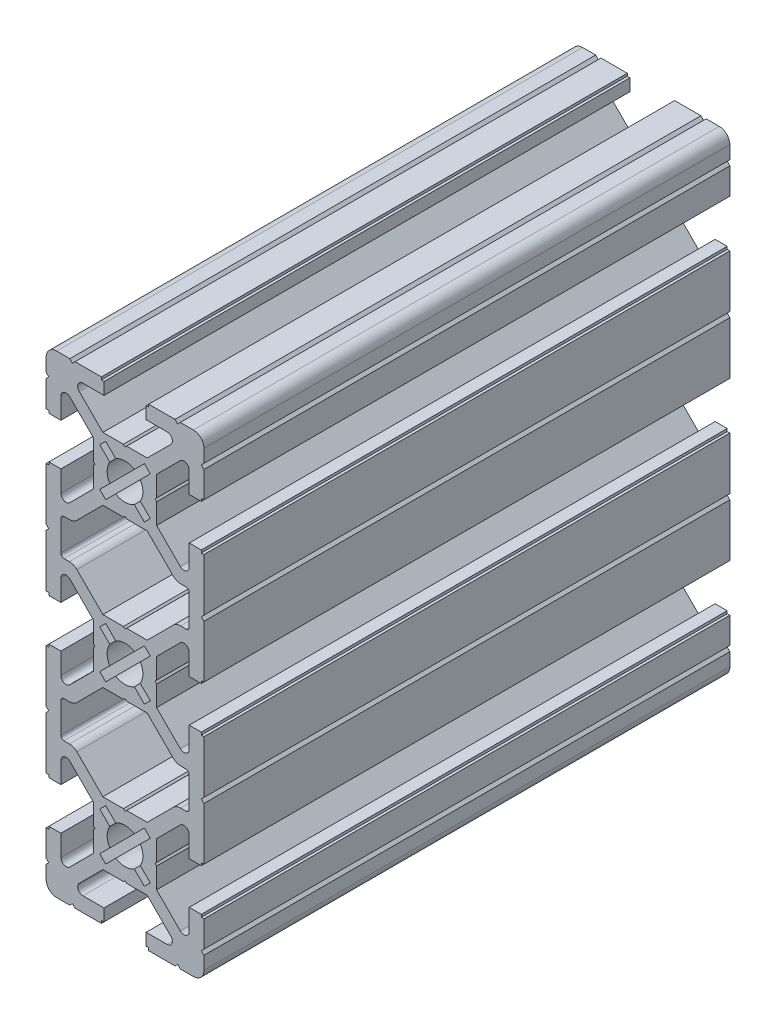
from build123d import *

# Parameters (mm, degrees)
Y_KSEKLIK_EKSTR_ZYON1_DEPTH = 100


with BuildPart() as part:
    # Çizim1 → Yükseklik-Ekstrüzyon1 (new body)
    with BuildSketch(Plane.XY.offset(100)):
        with BuildLine():
            Line((-4.214213564, 36), (-8.70710678, 40.492893215))
            ThreePointArc((-8.70710678, 40.492893215), (-8.923879532, 41.582683434), (-7.999999995, 42.200000005))
            Line((-7.999999995, 42.200000005), (-4.000000001, 42.200000005))
            Line((-4.000000001, 42.200000005), (-4.000000001, 44.500000001))
            Line((-4.000000001, 44.500000001), (-4.500000001, 44.500000001))
            Line((-4.500000001, 44.500000001), (-4.500000001, 44.999999999))
            Line((-4.500000001, 44.999999999), (-9.500000003, 44.999999999))
            Line((-9.500000003, 44.999999999), (-10.000000002, 44.499999999))
            Line((-10.000000002, 44.499999999), (-10.500000001, 44.999999999))
            Line((-10.500000001, 44.999999999), (-13, 44.999999999))
            ThreePointArc((-13, 44.999999999), (-14.414213562, 44.414213561), (-15, 42.999999999))
            Line((-15, 42.999999999), (-15, 40.5))
            Line((-15, 40.5), (-14.500000001, 40.000000001))
            Line((-14.500000001, 40.000000001), (-15, 39.500000001))
            Line((-15, 39.500000001), (-15, 34.5))
            Line((-15, 34.5), (-14.5, 34.5))
            Line((-14.5, 34.5), (-14.5, 34))
            Line((-14.5, 34), (-12.200000005, 34))
            Line((-12.200000005, 34), (-12.200000005, 37.999999994))
            ThreePointArc((-12.200000005, 37.999999994), (-11.582683434, 38.923879532), (-10.492893215, 38.707106779))
            Line((-10.492893215, 38.707106779), (-6, 34.214213564))
            Line((-6, 34.214213564), (-6, 30.312520901))
            Line((-6, 30.312520901), (-5.7, 30))
            Line((-5.7, 30), (-6, 29.687479097))
            Line((-6, 29.687479097), (-6, 25.785786436))
            Line((-6, 25.785786436), (-10.492893215, 21.29289322))
            ThreePointArc((-10.492893215, 21.29289322), (-11.582683434, 21.076120468), (-12.200000005, 22.000000005))
            Line((-12.200000005, 22.000000005), (-12.200000005, 26))
            Line((-12.200000005, 26), (-14.5, 26))
            Line((-14.5, 26), (-14.5, 25.5))
            Line((-14.5, 25.5), (-15, 25.5))
            Line((-15, 25.5), (-15, 15.499999999))
            Line((-15, 15.499999999), (-14.5, 14.999999999))
            Line((-14.5, 14.999999999), (-15, 14.499999999))
            Line((-15, 14.499999999), (-15, 4.5))
            Line((-15, 4.5), (-14.5, 4.5))
            Line((-14.5, 4.5), (-14.5, 4))
            Line((-14.5, 4), (-12.200000005, 4))
            Line((-12.200000005, 4), (-12.200000005, 7.999999994))
            ThreePointArc((-12.200000005, 7.999999994), (-11.582683434, 8.923879532), (-10.492893215, 8.707106779))
            Line((-10.492893215, 8.707106779), (-6, 4.214213564))
            Line((-6, 4.214213564), (-6, 0.312520903))
            Line((-6, 0.312520903), (-5.7, 0))
            Line((-5.7, 0), (-6, -0.312520901))
            Line((-6, -0.312520901), (-6, -4.214213564))
            Line((-6, -4.214213564), (-10.492893215, -8.70710678))
            ThreePointArc((-10.492893215, -8.70710678), (-11.582683434, -8.923879532), (-12.200000005, -7.999999995))
            Line((-12.200000005, -7.999999995), (-12.200000005, -4))
            Line((-12.200000005, -4), (-14.5, -4))
            Line((-14.5, -4), (-14.5, -4.5))
            Line((-14.5, -4.5), (-15, -4.5))
            Line((-15, -4.5), (-15, -14.499999999))
            Line((-15, -14.499999999), (-14.5, -14.999999999))
            Line((-14.5, -14.999999999), (-15, -15.499999999))
            Line((-15, -15.499999999), (-15, -25.5))
            Line((-15, -25.5), (-14.5, -25.5))
            Line((-14.5, -25.5), (-14.5, -26))
            Line((-14.5, -26), (-12.200000005, -26))
            Line((-12.200000005, -26), (-12.200000005, -22.000000006))
            ThreePointArc((-12.200000005, -22.000000006), (-11.582683434, -21.076120468), (-10.492893215, -21.292893221))
            Line((-10.492893215, -21.292893221), (-6, -25.785786436))
            Line((-6, -25.785786436), (-6, -29.687479097))
            Line((-6, -29.687479097), (-5.7, -30))
            Line((-5.7, -30), (-6, -30.312520901))
            Line((-6, -30.312520901), (-6, -34.214213564))
            Line((-6, -34.214213564), (-10.492893215, -38.70710678))
            ThreePointArc((-10.492893215, -38.70710678), (-11.582683434, -38.923879532), (-12.200000005, -37.999999995))
            Line((-12.200000005, -37.999999995), (-12.200000005, -34))
            Line((-12.200000005, -34), (-14.5, -34))
            Line((-14.5, -34), (-14.5, -34.5))
            Line((-14.5, -34.5), (-15, -34.5))
            Line((-15, -34.5), (-15, -39.500000001))
            Line((-15, -39.500000001), (-14.500000001, -40.000000001))
            Line((-14.500000001, -40.000000001), (-15, -40.5))
            Line((-15, -40.5), (-15, -42.999999999))
            ThreePointArc((-15, -42.999999999), (-14.414213562, -44.414213562), (-13, -44.999999999))
            Line((-13, -44.999999999), (-10.500000001, -44.999999999))
            Line((-10.500000001, -44.999999999), (-10.000000001, -44.5))
            Line((-10.000000001, -44.5), (-9.500000002, -44.999999999))
            Line((-9.500000002, -44.999999999), (-4.500000001, -44.999999999))
            Line((-4.500000001, -44.999999999), (-4.500000001, -44.499999999))
            Line((-4.500000001, -44.499999999), (-4.000000001, -44.499999999))
            Line((-4.000000001, -44.499999999), (-4.000000001, -42.200000005))
            Line((-4.000000001, -42.200000005), (-7.999999995, -42.200000005))
            ThreePointArc((-7.999999995, -42.200000005), (-8.923879532, -41.582683434), (-8.70710678, -40.492893215))
            Line((-8.70710678, -40.492893215), (-4.214213564, -36))
            Line((-4.214213564, -36), (-0.312520903, -36))
            Line((-0.312520903, -36), (0, -35.7))
            Line((0, -35.7), (0.312520901, -36))
            Line((0.312520901, -36), (4.214213564, -36))
            Line((4.214213564, -36), (8.70710678, -40.492893215))
            ThreePointArc((8.70710678, -40.492893215), (8.923879532, -41.582683434), (7.999999995, -42.200000005))
            Line((7.999999995, -42.200000005), (3.999999999, -42.200000005))
            Line((3.999999999, -42.200000005), (3.999999999, -44.499999999))
            Line((3.999999999, -44.499999999), (4.499999999, -44.499999999))
            Line((4.499999999, -44.499999999), (4.499999999, -44.999999999))
            Line((4.499999999, -44.999999999), (9.500000001, -44.999999999))
            Line((9.500000001, -44.999999999), (10, -44.5))
            Line((10, -44.5), (10.499999999, -44.999999999))
            Line((10.499999999, -44.999999999), (12.999999998, -44.999999999))
            ThreePointArc((12.999999998, -44.999999999), (14.41421356, -44.414213562), (14.999999998, -42.999999999))
            Line((14.999999998, -42.999999999), (14.999999998, -40.499999999))
            Line((14.999999998, -40.499999999), (14.499999999, -40.000000001))
            Line((14.499999999, -40.000000001), (14.999999998, -39.500000002))
            Line((14.999999998, -39.500000002), (14.999999998, -34.5))
            Line((14.999999998, -34.5), (14.5, -34.5))
            Line((14.5, -34.5), (14.5, -34))
            Line((14.5, -34), (12.200000005, -34))
            Line((12.200000005, -34), (12.200000005, -37.999999995))
            ThreePointArc((12.200000005, -37.999999995), (11.582683434, -38.923879532), (10.492893215, -38.70710678))
            Line((10.492893215, -38.70710678), (6, -34.214213564))
            Line((6, -34.214213564), (6, -30.312520903))
            Line((6, -30.312520903), (5.7, -30))
            Line((5.7, -30), (6, -29.687479099))
            Line((6, -29.687479099), (6, -25.785786436))
            Line((6, -25.785786436), (10.492893215, -21.29289322))
            ThreePointArc((10.492893215, -21.29289322), (11.582683434, -21.076120468), (12.200000005, -22.000000005))
            Line((12.200000005, -22.000000005), (12.200000005, -26))
            Line((12.200000005, -26), (14.5, -26))
            Line((14.5, -26), (14.5, -25.5))
            Line((14.5, -25.5), (14.999999998, -25.5))
            Line((14.999999998, -25.5), (14.999999998, -15.499999999))
            Line((14.999999998, -15.499999999), (14.499999998, -14.999999999))
            Line((14.499999998, -14.999999999), (14.999999998, -14.499999999))
            Line((14.999999998, -14.499999999), (14.999999998, -4.5))
            Line((14.999999998, -4.5), (14.5, -4.5))
            Line((14.5, -4.5), (14.5, -4))
            Line((14.5, -4), (12.200000005, -4))
            Line((12.200000005, -4), (12.200000005, -7.999999995))
            ThreePointArc((12.200000005, -7.999999995), (11.582683434, -8.923879532), (10.492893215, -8.707106779))
            Line((10.492893215, -8.707106779), (6, -4.214213564))
            Line((6, -4.214213564), (6, -0.312520903))
            Line((6, -0.312520903), (5.7, 0))
            Line((5.7, 0), (6, 0.312520901))
            Line((6, 0.312520901), (6, 4.214213564))
            Line((6, 4.214213564), (10.492893215, 8.70710678))
            ThreePointArc((10.492893215, 8.70710678), (11.582683434, 8.923879532), (12.200000005, 7.999999995))
            Line((12.200000005, 7.999999995), (12.200000005, 4))
            Line((12.200000005, 4), (14.5, 4))
            Line((14.5, 4), (14.5, 4.5))
            Line((14.5, 4.5), (14.999999998, 4.5))
            Line((14.999999998, 4.5), (14.999999998, 14.5))
            Line((14.999999998, 14.5), (14.499999998, 15))
            Line((14.499999998, 15), (14.999999998, 15.5))
            Line((14.999999998, 15.5), (14.999999998, 25.5))
            Line((14.999999998, 25.5), (14.5, 25.5))
            Line((14.5, 25.5), (14.5, 26))
            Line((14.5, 26), (12.200000005, 26))
            Line((12.200000005, 26), (12.200000005, 22.000000006))
            ThreePointArc((12.200000005, 22.000000006), (11.582683434, 21.076120468), (10.492893215, 21.292893221))
            Line((10.492893215, 21.292893221), (6, 25.785786436))
            Line((6, 25.785786436), (6, 29.687479099))
            Line((6, 29.687479099), (5.7, 30))
            Line((5.7, 30), (6, 30.312520903))
            Line((6, 30.312520903), (6, 34.214213564))
            Line((6, 34.214213564), (10.492893215, 38.70710678))
            ThreePointArc((10.492893215, 38.70710678), (11.582683434, 38.923879532), (12.200000005, 37.999999995))
            Line((12.200000005, 37.999999995), (12.200000005, 34))
            Line((12.200000005, 34), (14.5, 34))
            Line((14.5, 34), (14.5, 34.5))
            Line((14.5, 34.5), (14.999999998, 34.5))
            Line((14.999999998, 34.5), (14.999999998, 39.500000002))
            Line((14.999999998, 39.500000002), (14.499999999, 40.000000001))
            Line((14.499999999, 40.000000001), (14.999999998, 40.500000001))
            Line((14.999999998, 40.500000001), (14.999999998, 42.999999999))
            ThreePointArc((14.999999998, 42.999999999), (14.41421356, 44.414213561), (12.999999998, 44.999999999))
            Line((12.999999998, 44.999999999), (10.499999999, 44.999999999))
            Line((10.499999999, 44.999999999), (9.999999999, 44.499999999))
            Line((9.999999999, 44.499999999), (9.5, 44.999999999))
            Line((9.5, 44.999999999), (4.499999999, 44.999999999))
            Line((4.499999999, 44.999999999), (4.499999999, 44.500000001))
            Line((4.499999999, 44.500000001), (3.999999999, 44.500000001))
            Line((3.999999999, 44.500000001), (3.999999999, 42.200000005))
            Line((3.999999999, 42.200000005), (7.999999994, 42.200000005))
            ThreePointArc((7.999999994, 42.200000005), (8.923879532, 41.582683434), (8.707106779, 40.492893215))
            Line((8.707106779, 40.492893215), (4.214213564, 36))
            Line((4.214213564, 36), (0.312520901, 36))
            Line((0.312520901, 36), (0, 35.7))
            Line((0, 35.7), (-0.312520903, 36))
            Line((-0.312520903, 36), (-4.214213564, 36))
        make_face()
        with BuildLine():
            Line((-2.902349714, 31.770978864), (-4.808326112, 33.676955262))
            Line((-4.808326112, 33.676955262), (-3.676955262, 34.808326112))
            Line((-3.676955262, 34.808326112), (-1.770978864, 32.902349714))
            ThreePointArc((-1.770978864, 32.902349714), (0, 33.4), (1.770978864, 32.902349714))
            Line((1.770978864, 32.902349714), (3.676955262, 34.808326112))
            Line((3.676955262, 34.808326112), (4.808326112, 33.676955262))
            Line((4.808326112, 33.676955262), (2.902349714, 31.770978864))
            ThreePointArc((2.902349714, 31.770978864), (3.4, 30), (2.902349714, 28.229021136))
            Line((2.902349714, 28.229021136), (4.808326112, 26.323044738))
            Line((4.808326112, 26.323044738), (3.676955262, 25.191673888))
            Line((3.676955262, 25.191673888), (1.770978864, 27.097650286))
            ThreePointArc((1.770978864, 27.097650286), (0, 26.6), (-1.770978864, 27.097650286))
            Line((-1.770978864, 27.097650286), (-3.676955262, 25.191673888))
            Line((-3.676955262, 25.191673888), (-4.808326112, 26.323044738))
            Line((-4.808326112, 26.323044738), (-2.902349714, 28.229021136))
            ThreePointArc((-2.902349714, 28.229021136), (-3.4, 30), (-2.902349714, 31.770978864))
        make_face(mode=Mode.SUBTRACT)
        with BuildLine():
            Line((-2.902349714, 1.770978864), (-4.808326112, 3.676955262))
            Line((-4.808326112, 3.676955262), (-3.676955262, 4.808326112))
            Line((-3.676955262, 4.808326112), (-1.770978864, 2.902349714))
            ThreePointArc((-1.770978864, 2.902349714), (0, 3.4), (1.770978864, 2.902349714))
            Line((1.770978864, 2.902349714), (3.676955262, 4.808326112))
            Line((3.676955262, 4.808326112), (4.808326112, 3.676955262))
            Line((4.808326112, 3.676955262), (2.902349714, 1.770978864))
            ThreePointArc((2.902349714, 1.770978864), (3.4, 0), (2.902349714, -1.770978864))
            Line((2.902349714, -1.770978864), (4.808326112, -3.676955262))
            Line((4.808326112, -3.676955262), (3.676955262, -4.808326112))
            Line((3.676955262, -4.808326112), (1.770978864, -2.902349714))
            ThreePointArc((1.770978864, -2.902349714), (0, -3.4), (-1.770978864, -2.902349714))
            Line((-1.770978864, -2.902349714), (-3.676955262, -4.808326112))
            Line((-3.676955262, -4.808326112), (-4.808326112, -3.676955262))
            Line((-4.808326112, -3.676955262), (-2.902349714, -1.770978864))
            ThreePointArc((-2.902349714, -1.770978864), (-3.4, 0), (-2.902349714, 1.770978864))
        make_face(mode=Mode.SUBTRACT)
        with BuildLine():
            Line((-2.902349714, -28.229021136), (-4.808326112, -26.323044738))
            Line((-4.808326112, -26.323044738), (-3.676955262, -25.191673888))
            Line((-3.676955262, -25.191673888), (-1.770978864, -27.097650286))
            ThreePointArc((-1.770978864, -27.097650286), (0, -26.6), (1.770978864, -27.097650286))
            Line((1.770978864, -27.097650286), (3.676955262, -25.191673888))
            Line((3.676955262, -25.191673888), (4.808326112, -26.323044738))
            Line((4.808326112, -26.323044738), (2.902349714, -28.229021136))
            ThreePointArc((2.902349714, -28.229021136), (3.4, -30), (2.902349714, -31.770978864))
            Line((2.902349714, -31.770978864), (4.808326112, -33.676955262))
            Line((4.808326112, -33.676955262), (3.676955262, -34.808326112))
            Line((3.676955262, -34.808326112), (1.770978864, -32.902349714))
            ThreePointArc((1.770978864, -32.902349714), (0, -33.4), (-1.770978864, -32.902349714))
            Line((-1.770978864, -32.902349714), (-3.676955262, -34.808326112))
            Line((-3.676955262, -34.808326112), (-4.808326112, -33.676955262))
            Line((-4.808326112, -33.676955262), (-2.902349714, -31.770978864))
            ThreePointArc((-2.902349714, -31.770978864), (-3.4, -30), (-2.902349714, -28.229021136))
        make_face(mode=Mode.SUBTRACT)
        with BuildLine():
            Line((-9.158427127, 19.055786438), (-4.214213564, 24))
            Line((-4.214213564, 24), (-0.312520901, 24))
            Line((-0.312520901, 24), (0, 24.3))
            Line((0, 24.3), (0.312520903, 24))
            Line((0.312520903, 24), (4.214213564, 24))
            Line((4.214213564, 24), (9.158427127, 19.055786438))
            ThreePointArc((9.158427127, 19.055786438), (9.807273824, 18.622240935), (10.572640689, 18.47))
            Line((10.572640689, 18.47), (11.600000005, 18.47))
            ThreePointArc((11.600000005, 18.47), (12.024264074, 18.294264069), (12.200000005, 17.87))
            Line((12.200000005, 17.87), (12.200000005, 12.13))
            ThreePointArc((12.200000005, 12.13), (12.024264074, 11.705735931), (11.600000005, 11.53))
            Line((11.600000005, 11.53), (10.572640689, 11.53))
            ThreePointArc((10.572640689, 11.53), (9.807273824, 11.377759065), (9.158427127, 10.944213562))
            Line((9.158427127, 10.944213562), (4.214213564, 6))
            Line((4.214213564, 6), (0.312520903, 6))
            Line((0.312520903, 6), (0, 5.7))
            Line((0, 5.7), (-0.312520901, 6))
            Line((-0.312520901, 6), (-4.214213564, 6))
            Line((-4.214213564, 6), (-9.158427127, 10.944213562))
            ThreePointArc((-9.158427127, 10.944213562), (-9.807273824, 11.377759065), (-10.572640689, 11.53))
            Line((-10.572640689, 11.53), (-11.600000005, 11.53))
            ThreePointArc((-11.600000005, 11.53), (-12.024264074, 11.705735931), (-12.200000005, 12.13))
            Line((-12.200000005, 12.13), (-12.200000005, 17.87))
            ThreePointArc((-12.200000005, 17.87), (-12.024264074, 18.294264069), (-11.600000005, 18.47))
            Line((-11.600000005, 18.47), (-10.572640689, 18.47))
            ThreePointArc((-10.572640689, 18.47), (-9.807273824, 18.622240935), (-9.158427127, 19.055786438))
        make_face(mode=Mode.SUBTRACT)
        with BuildLine():
            Line((-9.158427127, -10.944213562), (-4.214213564, -6))
            Line((-4.214213564, -6), (-0.312520901, -6))
            Line((-0.312520901, -6), (0, -5.7))
            Line((0, -5.7), (0.312520903, -6))
            Line((0.312520903, -6), (4.214213564, -6))
            Line((4.214213564, -6), (9.158427127, -10.944213562))
            ThreePointArc((9.158427127, -10.944213562), (9.807273824, -11.377759065), (10.572640689, -11.53))
            Line((10.572640689, -11.53), (11.600000005, -11.53))
            ThreePointArc((11.600000005, -11.53), (12.024264074, -11.705735931), (12.200000005, -12.13))
            Line((12.200000005, -12.13), (12.200000005, -17.87))
            ThreePointArc((12.200000005, -17.87), (12.024264074, -18.294264069), (11.600000005, -18.47))
            Line((11.600000005, -18.47), (10.572640689, -18.47))
            ThreePointArc((10.572640689, -18.47), (9.807273824, -18.622240935), (9.158427127, -19.055786438))
            Line((9.158427127, -19.055786438), (4.214213564, -24))
            Line((4.214213564, -24), (0.312520903, -24))
            Line((0.312520903, -24), (0, -24.3))
            Line((0, -24.3), (-0.312520901, -24))
            Line((-0.312520901, -24), (-4.214213564, -24))
            Line((-4.214213564, -24), (-9.158427127, -19.055786438))
            ThreePointArc((-9.158427127, -19.055786438), (-9.807273824, -18.622240935), (-10.572640689, -18.47))
            Line((-10.572640689, -18.47), (-11.600000005, -18.47))
            ThreePointArc((-11.600000005, -18.47), (-12.024264074, -18.294264069), (-12.200000005, -17.87))
            Line((-12.200000005, -17.87), (-12.200000005, -12.13))
            ThreePointArc((-12.200000005, -12.13), (-12.024264074, -11.705735931), (-11.600000005, -11.53))
            Line((-11.600000005, -11.53), (-10.572640689, -11.53))
            ThreePointArc((-10.572640689, -11.53), (-9.807273824, -11.377759065), (-9.158427127, -10.944213562))
        make_face(mode=Mode.SUBTRACT)
    extrude(amount=-Y_KSEKLIK_EKSTR_ZYON1_DEPTH)


solid = part.part
